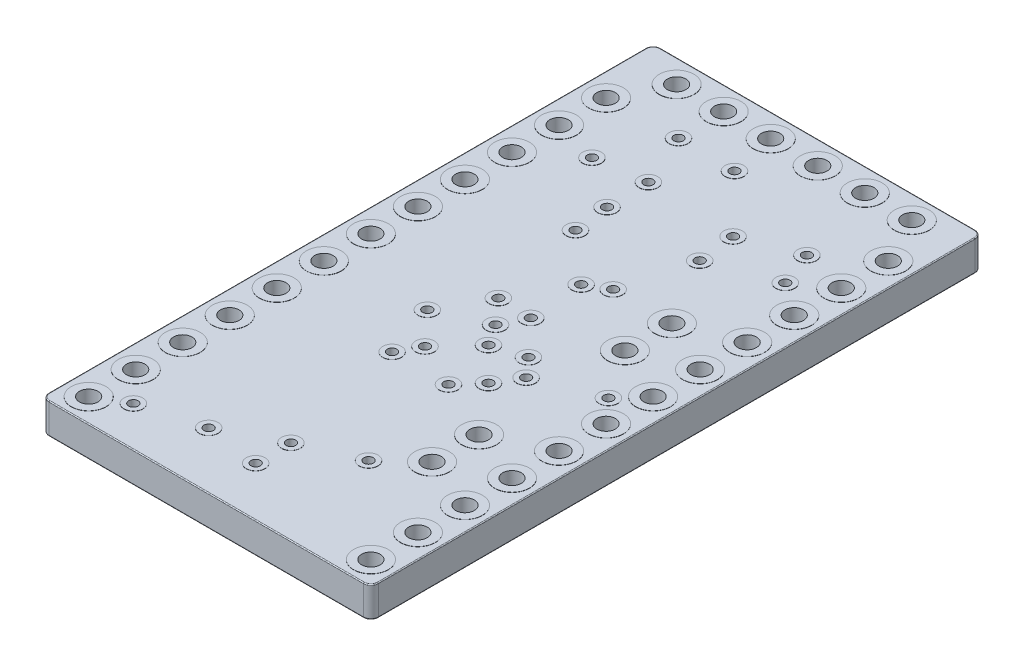
from build123d import *

# Parameters (mm, degrees)
SKETCH1_W           = 17.78
SKETCH1_H           = 33.02
BOARD_DEPTH         = 1.65
HEADER_HOLES_R      = 0.5
CUT_EXTRUDE1_DEPTH  = 2.65
SKETCH3_R           = 0.254
CUT_EXTRUDE2_DEPTH  = 2.65
SKETCH4_R           = 0.508
SKETCH4_R_2         = 0.254
BOSS_EXTRUDE1_DEPTH = 0.01
SKETCH5_R           = 0.94
SKETCH5_R_2         = 0.5
BOSS_EXTRUDE2_DEPTH = 0.01
FILLET1_R           = 0.4
FILLET2_R           = 0.05


with BuildPart() as part:
    # Sketch1 → Board (new body)
    with BuildSketch(Plane(origin=(0, 0, 0), x_dir=(1, 0, 0), z_dir=(0, 1, 0))):
        with Locations((8.89, 16.51)):
            Rectangle(SKETCH1_W, SKETCH1_H)
    extrude(amount=BOARD_DEPTH)

    # Header Holes → Cut-Extrude1 (cut, through all)
    with BuildSketch(Plane(origin=(0, 1.65, 0), x_dir=(1, 0, 0), z_dir=(0, 1, 0))):
        with Locations((1.27, 1.27)):
            Circle(HEADER_HOLES_R)
        with Locations((16.51, 1.27)):
            Circle(HEADER_HOLES_R)
        with Locations((1.27, 3.81)):
            Circle(HEADER_HOLES_R)
        with Locations((16.51, 3.81)):
            Circle(HEADER_HOLES_R)
        with Locations((1.27, 6.35)):
            Circle(HEADER_HOLES_R)
        with Locations((16.51, 6.35)):
            Circle(HEADER_HOLES_R)
        with Locations((1.27, 8.89)):
            Circle(HEADER_HOLES_R)
        with Locations((16.51, 8.89)):
            Circle(HEADER_HOLES_R)
        with Locations((1.27, 11.43)):
            Circle(HEADER_HOLES_R)
        with Locations((16.51, 11.43)):
            Circle(HEADER_HOLES_R)
        with Locations((1.27, 13.97)):
            Circle(HEADER_HOLES_R)
        with Locations((16.51, 13.97)):
            Circle(HEADER_HOLES_R)
        with Locations((1.27, 16.51)):
            Circle(HEADER_HOLES_R)
        with Locations((16.51, 16.51)):
            Circle(HEADER_HOLES_R)
        with Locations((1.27, 19.05)):
            Circle(HEADER_HOLES_R)
        with Locations((16.51, 19.05)):
            Circle(HEADER_HOLES_R)
        with Locations((1.27, 21.59)):
            Circle(HEADER_HOLES_R)
        with Locations((16.51, 21.59)):
            Circle(HEADER_HOLES_R)
        with Locations((1.27, 24.13)):
            Circle(HEADER_HOLES_R)
        with Locations((16.51, 24.13)):
            Circle(HEADER_HOLES_R)
        with Locations((1.27, 26.67)):
            Circle(HEADER_HOLES_R)
        with Locations((16.51, 26.67)):
            Circle(HEADER_HOLES_R)
        with Locations((1.27, 29.21)):
            Circle(HEADER_HOLES_R)
        with Locations((16.51, 29.21)):
            Circle(HEADER_HOLES_R)
        with Locations((13.589, 7.493)):
            Circle(HEADER_HOLES_R)
        with Locations((13.589, 10.033)):
            Circle(HEADER_HOLES_R)
        with Locations((13.589, 17.907)):
            Circle(HEADER_HOLES_R)
        with Locations((13.589, 20.447)):
            Circle(HEADER_HOLES_R)
        with Locations((15.24, 31.75)):
            Circle(HEADER_HOLES_R)
        with Locations((12.7, 31.75)):
            Circle(HEADER_HOLES_R)
        with Locations((10.16, 31.75)):
            Circle(HEADER_HOLES_R)
        with Locations((7.62, 31.75)):
            Circle(HEADER_HOLES_R)
        with Locations((5.08, 31.75)):
            Circle(HEADER_HOLES_R)
        with Locations((2.54, 31.75)):
            Circle(HEADER_HOLES_R)
    extrude(amount=-CUT_EXTRUDE1_DEPTH, mode=Mode.SUBTRACT)

    # Sketch3 → Cut-Extrude2 (cut, through all)
    with BuildSketch(Plane(origin=(0, 1.65, 0), x_dir=(1, 0, 0), z_dir=(0, 1, 0))):
        with Locations((2.794, 2.159)):
            Circle(SKETCH3_R)
        with Locations((5.969, 3.048)):
            Circle(SKETCH3_R)
        with Locations((8.89, 4.572)):
            Circle(SKETCH3_R)
        with Locations((8.89, 2.667)):
            Circle(SKETCH3_R)
        with Locations((11.811, 5.842)):
            Circle(SKETCH3_R)
        with Locations((7.366, 11.557)):
            Circle(SKETCH3_R)
        with Locations((8.001, 12.7)):
            Circle(SKETCH3_R)
        with Locations((10.414, 11.557)):
            Circle(SKETCH3_R)
        with Locations((11.43, 12.7)):
            Circle(SKETCH3_R)
        with Locations((6.35, 14.478)):
            Circle(SKETCH3_R)
        with Locations((12.192, 13.97)):
            Circle(SKETCH3_R)
        with Locations((11.303, 14.986)):
            Circle(SKETCH3_R)
        with Locations((8.89, 15.621)):
            Circle(SKETCH3_R)
        with Locations((9.525, 16.891)):
            Circle(SKETCH3_R)
        with Locations((15.367, 15.24)):
            Circle(SKETCH3_R)
        with Locations((7.7216, 16.9418)):
            Circle(SKETCH3_R)
        with Locations((9.652, 14.478)):
            Circle(SKETCH3_R)
        with Locations((9.3218, 19.812)):
            Circle(SKETCH3_R)
        with Locations((10.414, 20.447)):
            Circle(SKETCH3_R)
        with Locations((6.6294, 22.1996)):
            Circle(SKETCH3_R)
        with Locations((6.4008, 24.13)):
            Circle(SKETCH3_R)
        with Locations((6.35, 26.416)):
            Circle(SKETCH3_R)
        with Locations((3.683, 26.035)):
            Circle(SKETCH3_R)
        with Locations((5.1054, 29.2862)):
            Circle(SKETCH3_R)
        with Locations((8.1534, 29.2608)):
            Circle(SKETCH3_R)
        with Locations((11.4046, 24.13)):
            Circle(SKETCH3_R)
        with Locations((11.176, 26.162)):
            Circle(SKETCH3_R)
        with Locations((14.7574, 25.4)):
            Circle(SKETCH3_R)
        with Locations((14.0462, 27.2796)):
            Circle(SKETCH3_R)
    extrude(amount=-CUT_EXTRUDE2_DEPTH, mode=Mode.SUBTRACT)

    # Sketch4 → Boss-Extrude1 (add)
    with BuildSketch(Plane(origin=(0, 1.65, 0), x_dir=(1, 0, 0), z_dir=(0, 1, 0))):
        with Locations((2.794, 2.159)):
            Circle(SKETCH4_R)
        with Locations((2.794, 2.159)):
            Circle(SKETCH4_R_2, mode=Mode.SUBTRACT)
        with Locations((5.969, 3.048)):
            Circle(SKETCH4_R)
        with Locations((5.969, 3.048)):
            Circle(SKETCH4_R_2, mode=Mode.SUBTRACT)
        with Locations((8.89, 4.572)):
            Circle(SKETCH4_R)
        with Locations((8.89, 4.572)):
            Circle(SKETCH4_R_2, mode=Mode.SUBTRACT)
        with Locations((8.89, 2.667)):
            Circle(SKETCH4_R)
        with Locations((8.89, 2.667)):
            Circle(SKETCH4_R_2, mode=Mode.SUBTRACT)
        with Locations((11.811, 5.842)):
            Circle(SKETCH4_R)
        with Locations((11.811, 5.842)):
            Circle(SKETCH4_R_2, mode=Mode.SUBTRACT)
        with Locations((7.366, 11.557)):
            Circle(SKETCH4_R)
        with Locations((7.366, 11.557)):
            Circle(SKETCH4_R_2, mode=Mode.SUBTRACT)
        with Locations((8.001, 12.7)):
            Circle(SKETCH4_R)
        with Locations((8.001, 12.7)):
            Circle(SKETCH4_R_2, mode=Mode.SUBTRACT)
        with Locations((10.414, 11.557)):
            Circle(SKETCH4_R)
        with Locations((10.414, 11.557)):
            Circle(SKETCH4_R_2, mode=Mode.SUBTRACT)
        with Locations((11.43, 12.7)):
            Circle(SKETCH4_R)
        with Locations((11.43, 12.7)):
            Circle(SKETCH4_R_2, mode=Mode.SUBTRACT)
        with Locations((9.652, 14.478)):
            Circle(SKETCH4_R)
        with Locations((9.652, 14.478)):
            Circle(SKETCH4_R_2, mode=Mode.SUBTRACT)
        with Locations((6.35, 14.478)):
            Circle(SKETCH4_R)
        with Locations((6.35, 14.478)):
            Circle(SKETCH4_R_2, mode=Mode.SUBTRACT)
        with Locations((11.303, 14.986)):
            Circle(SKETCH4_R)
        with Locations((11.303, 14.986)):
            Circle(SKETCH4_R_2, mode=Mode.SUBTRACT)
        with Locations((12.192, 13.97)):
            Circle(SKETCH4_R)
        with Locations((12.192, 13.97)):
            Circle(SKETCH4_R_2, mode=Mode.SUBTRACT)
        with Locations((15.367, 15.24)):
            Circle(SKETCH4_R)
        with Locations((15.367, 15.24)):
            Circle(SKETCH4_R_2, mode=Mode.SUBTRACT)
        with Locations((8.89, 15.621)):
            Circle(SKETCH4_R)
        with Locations((8.89, 15.621)):
            Circle(SKETCH4_R_2, mode=Mode.SUBTRACT)
        with Locations((7.7216, 16.9418)):
            Circle(SKETCH4_R)
        with Locations((7.7216, 16.9418)):
            Circle(SKETCH4_R_2, mode=Mode.SUBTRACT)
        with Locations((9.525, 16.891)):
            Circle(SKETCH4_R)
        with Locations((9.525, 16.891)):
            Circle(SKETCH4_R_2, mode=Mode.SUBTRACT)
        with Locations((9.3218, 19.812)):
            Circle(SKETCH4_R)
        with Locations((9.3218, 19.812)):
            Circle(SKETCH4_R_2, mode=Mode.SUBTRACT)
        with Locations((10.414, 20.447)):
            Circle(SKETCH4_R)
        with Locations((10.414, 20.447)):
            Circle(SKETCH4_R_2, mode=Mode.SUBTRACT)
        with Locations((6.6294, 22.1996)):
            Circle(SKETCH4_R)
        with Locations((6.6294, 22.1996)):
            Circle(SKETCH4_R_2, mode=Mode.SUBTRACT)
        with Locations((6.4008, 24.13)):
            Circle(SKETCH4_R)
        with Locations((6.4008, 24.13)):
            Circle(SKETCH4_R_2, mode=Mode.SUBTRACT)
        with Locations((3.683, 26.035)):
            Circle(SKETCH4_R)
        with Locations((3.683, 26.035)):
            Circle(SKETCH4_R_2, mode=Mode.SUBTRACT)
        with Locations((6.35, 26.416)):
            Circle(SKETCH4_R)
        with Locations((6.35, 26.416)):
            Circle(SKETCH4_R_2, mode=Mode.SUBTRACT)
        with Locations((11.4046, 24.13)):
            Circle(SKETCH4_R)
        with Locations((11.4046, 24.13)):
            Circle(SKETCH4_R_2, mode=Mode.SUBTRACT)
        with Locations((11.176, 26.162)):
            Circle(SKETCH4_R)
        with Locations((11.176, 26.162)):
            Circle(SKETCH4_R_2, mode=Mode.SUBTRACT)
        with Locations((14.0462, 27.2796)):
            Circle(SKETCH4_R)
        with Locations((14.0462, 27.2796)):
            Circle(SKETCH4_R_2, mode=Mode.SUBTRACT)
        with Locations((14.7574, 25.4)):
            Circle(SKETCH4_R)
        with Locations((14.7574, 25.4)):
            Circle(SKETCH4_R_2, mode=Mode.SUBTRACT)
        with Locations((8.1534, 29.2608)):
            Circle(SKETCH4_R)
        with Locations((8.1534, 29.2608)):
            Circle(SKETCH4_R_2, mode=Mode.SUBTRACT)
        with Locations((5.1054, 29.2862)):
            Circle(SKETCH4_R)
        with Locations((5.1054, 29.2862)):
            Circle(SKETCH4_R_2, mode=Mode.SUBTRACT)
    boss_extrude1 = extrude(amount=BOSS_EXTRUDE1_DEPTH)

    # Sketch5 → Boss-Extrude2 (add)
    with BuildSketch(Plane(origin=(0, 1.65, 0), x_dir=(1, 0, 0), z_dir=(0, 1, 0))):
        with Locations((1.27, 1.27)):
            Circle(SKETCH5_R)
        with Locations((1.27, 1.27)):
            Circle(SKETCH5_R_2, mode=Mode.SUBTRACT)
        with Locations((1.27, 3.81)):
            Circle(SKETCH5_R)
        with Locations((1.27, 3.81)):
            Circle(SKETCH5_R_2, mode=Mode.SUBTRACT)
        with Locations((1.27, 6.35)):
            Circle(SKETCH5_R)
        with Locations((1.27, 6.35)):
            Circle(SKETCH5_R_2, mode=Mode.SUBTRACT)
        with Locations((1.27, 8.89)):
            Circle(SKETCH5_R)
        with Locations((1.27, 8.89)):
            Circle(SKETCH5_R_2, mode=Mode.SUBTRACT)
        with Locations((1.27, 11.43)):
            Circle(SKETCH5_R)
        with Locations((1.27, 11.43)):
            Circle(SKETCH5_R_2, mode=Mode.SUBTRACT)
        with Locations((1.27, 13.97)):
            Circle(SKETCH5_R)
        with Locations((1.27, 13.97)):
            Circle(SKETCH5_R_2, mode=Mode.SUBTRACT)
        with Locations((1.27, 16.51)):
            Circle(SKETCH5_R)
        with Locations((1.27, 16.51)):
            Circle(SKETCH5_R_2, mode=Mode.SUBTRACT)
        with Locations((1.27, 19.05)):
            Circle(SKETCH5_R)
        with Locations((1.27, 19.05)):
            Circle(SKETCH5_R_2, mode=Mode.SUBTRACT)
        with Locations((1.27, 21.59)):
            Circle(SKETCH5_R)
        with Locations((1.27, 21.59)):
            Circle(SKETCH5_R_2, mode=Mode.SUBTRACT)
        with Locations((1.27, 24.13)):
            Circle(SKETCH5_R)
        with Locations((1.27, 24.13)):
            Circle(SKETCH5_R_2, mode=Mode.SUBTRACT)
        with Locations((1.27, 26.67)):
            Circle(SKETCH5_R)
        with Locations((1.27, 26.67)):
            Circle(SKETCH5_R_2, mode=Mode.SUBTRACT)
        with Locations((1.27, 29.21)):
            Circle(SKETCH5_R)
        with Locations((1.27, 29.21)):
            Circle(SKETCH5_R_2, mode=Mode.SUBTRACT)
        with Locations((16.51, 29.21)):
            Circle(SKETCH5_R)
        with Locations((16.51, 29.21)):
            Circle(SKETCH5_R_2, mode=Mode.SUBTRACT)
        with Locations((16.51, 26.67)):
            Circle(SKETCH5_R)
        with Locations((16.51, 26.67)):
            Circle(SKETCH5_R_2, mode=Mode.SUBTRACT)
        with Locations((16.51, 24.13)):
            Circle(SKETCH5_R)
        with Locations((16.51, 24.13)):
            Circle(SKETCH5_R_2, mode=Mode.SUBTRACT)
        with Locations((16.51, 21.59)):
            Circle(SKETCH5_R)
        with Locations((16.51, 21.59)):
            Circle(SKETCH5_R_2, mode=Mode.SUBTRACT)
        with Locations((16.51, 19.05)):
            Circle(SKETCH5_R)
        with Locations((16.51, 19.05)):
            Circle(SKETCH5_R_2, mode=Mode.SUBTRACT)
        with Locations((16.51, 16.51)):
            Circle(SKETCH5_R)
        with Locations((16.51, 16.51)):
            Circle(SKETCH5_R_2, mode=Mode.SUBTRACT)
        with Locations((16.51, 13.97)):
            Circle(SKETCH5_R)
        with Locations((16.51, 13.97)):
            Circle(SKETCH5_R_2, mode=Mode.SUBTRACT)
        with Locations((16.51, 11.43)):
            Circle(SKETCH5_R)
        with Locations((16.51, 11.43)):
            Circle(SKETCH5_R_2, mode=Mode.SUBTRACT)
        with Locations((16.51, 8.89)):
            Circle(SKETCH5_R)
        with Locations((16.51, 8.89)):
            Circle(SKETCH5_R_2, mode=Mode.SUBTRACT)
        with Locations((16.51, 6.35)):
            Circle(SKETCH5_R)
        with Locations((16.51, 6.35)):
            Circle(SKETCH5_R_2, mode=Mode.SUBTRACT)
        with Locations((16.51, 3.81)):
            Circle(SKETCH5_R)
        with Locations((16.51, 3.81)):
            Circle(SKETCH5_R_2, mode=Mode.SUBTRACT)
        with Locations((16.51, 1.27)):
            Circle(SKETCH5_R)
        with Locations((16.51, 1.27)):
            Circle(SKETCH5_R_2, mode=Mode.SUBTRACT)
        with Locations((2.54, 31.75)):
            Circle(SKETCH5_R)
        with Locations((2.54, 31.75)):
            Circle(SKETCH5_R_2, mode=Mode.SUBTRACT)
        with Locations((5.08, 31.75)):
            Circle(SKETCH5_R)
        with Locations((5.08, 31.75)):
            Circle(SKETCH5_R_2, mode=Mode.SUBTRACT)
        with Locations((7.62, 31.75)):
            Circle(SKETCH5_R)
        with Locations((7.62, 31.75)):
            Circle(SKETCH5_R_2, mode=Mode.SUBTRACT)
        with Locations((10.16, 31.75)):
            Circle(SKETCH5_R)
        with Locations((10.16, 31.75)):
            Circle(SKETCH5_R_2, mode=Mode.SUBTRACT)
        with Locations((12.7, 31.75)):
            Circle(SKETCH5_R)
        with Locations((12.7, 31.75)):
            Circle(SKETCH5_R_2, mode=Mode.SUBTRACT)
        with Locations((15.24, 31.75)):
            Circle(SKETCH5_R)
        with Locations((15.24, 31.75)):
            Circle(SKETCH5_R_2, mode=Mode.SUBTRACT)
        with Locations((13.589, 10.033)):
            Circle(SKETCH5_R)
        with Locations((13.589, 10.033)):
            Circle(SKETCH5_R_2, mode=Mode.SUBTRACT)
        with Locations((13.589, 7.493)):
            Circle(SKETCH5_R)
        with Locations((13.589, 7.493)):
            Circle(SKETCH5_R_2, mode=Mode.SUBTRACT)
        with Locations((13.589, 20.447)):
            Circle(SKETCH5_R)
        with Locations((13.589, 20.447)):
            Circle(SKETCH5_R_2, mode=Mode.SUBTRACT)
        with Locations((13.589, 17.907)):
            Circle(SKETCH5_R)
        with Locations((13.589, 17.907)):
            Circle(SKETCH5_R_2, mode=Mode.SUBTRACT)
    boss_extrude2 = extrude(amount=BOSS_EXTRUDE2_DEPTH)

    # Mirror1: Boss-Extrude1, Boss-Extrude2 across plane
    add(boss_extrude1.mirror(Plane.ZX.offset(0.825)))
    add(boss_extrude2.mirror(Plane.ZX.offset(0.825)))

    # Fillet1
    fillet1_edges = [part.edges().sort_by_distance(p)[0] for p in [
        (0, 0.825, -33.02),
        (17.78, 0.825, -33.02),
        (17.78, 0.825, 0),
        (0, 0.825, 0),
    ]]
    fillet(fillet1_edges, radius=FILLET1_R)

    # Fillet2
    fillet2_edges = [part.edges().sort_by_distance(p)[0] for p in [
        (0, 0, -16.51),
        (0, 1.65, -16.51),
        (8.89, 0, -33.02),
        (17.78, 0, -16.51),
        (8.89, 0, 0),
        (17.662842712, 0, -0.117157288),
        (0.117157288, 0, -0.117157288),
        (17.662842712, 0, -32.902842712),
        (0.117157288, 0, -32.902842712),
        (8.89, 1.65, -33.02),
        (8.89, 1.65, 0),
        (17.78, 1.65, -16.51),
        (17.662842712, 1.65, -0.117157288),
        (0.117157288, 1.65, -0.117157288),
        (17.662842712, 1.65, -32.902842712),
        (0.117157288, 1.65, -32.902842712),
    ]]
    fillet(fillet2_edges, radius=FILLET2_R)


solid = part.part
